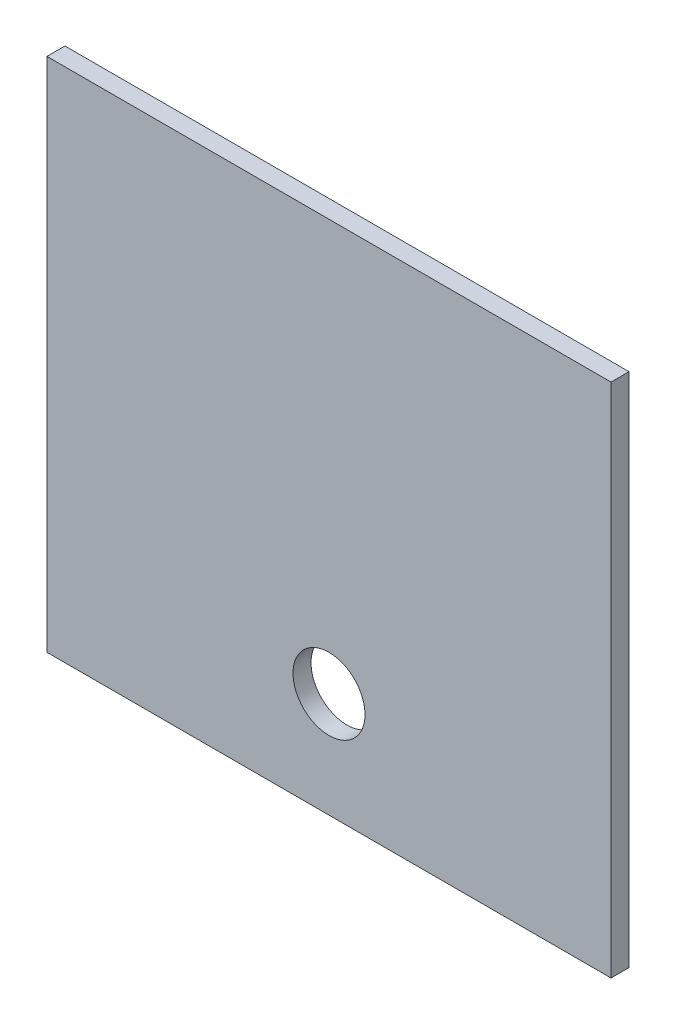
from build123d import *

# Parameters (mm, degrees)
SKETCH1_W           = 596.9
SKETCH1_H           = 304.8
BOSS_EXTRUDE1_DEPTH = 19.05
SKETCH2_W           = 596.9
SKETCH2_H           = 19.05
BOSS_EXTRUDE2_DEPTH = 25.4
SKETCH3_W           = 596.9
SKETCH3_H           = 19.05
BOSS_EXTRUDE3_DEPTH = 215.9
SKETCH4_R           = 38.1
CUT_EXTRUDE1_DEPTH  = 20.05


with BuildPart() as part:
    # Sketch1 → Boss-Extrude1 (new body)
    with BuildSketch(Plane.XY):
        Rectangle(SKETCH1_W, SKETCH1_H)
    extrude(amount=BOSS_EXTRUDE1_DEPTH)

    # Sketch2 → Boss-Extrude2 (add)
    with BuildSketch(Plane(origin=(0, 152.4, 0), x_dir=(1, 0, 0), z_dir=(0, 1, 0))):
        with Locations((0, -9.525)):
            Rectangle(SKETCH2_W, SKETCH2_H)
    extrude(amount=BOSS_EXTRUDE2_DEPTH)

    # Sketch3 → Boss-Extrude3 (add)
    with BuildSketch(Plane.XZ.offset(152.4)):
        with Locations((0, 9.525)):
            Rectangle(SKETCH3_W, SKETCH3_H)
    extrude(amount=BOSS_EXTRUDE3_DEPTH)

    # Sketch4 → Cut-Extrude1 (cut, through all)
    with BuildSketch(Plane.XY.offset(19.05)):
        with Locations((0, -257.175)):
            Circle(SKETCH4_R)
    extrude(amount=-CUT_EXTRUDE1_DEPTH, mode=Mode.SUBTRACT)


solid = part.part
